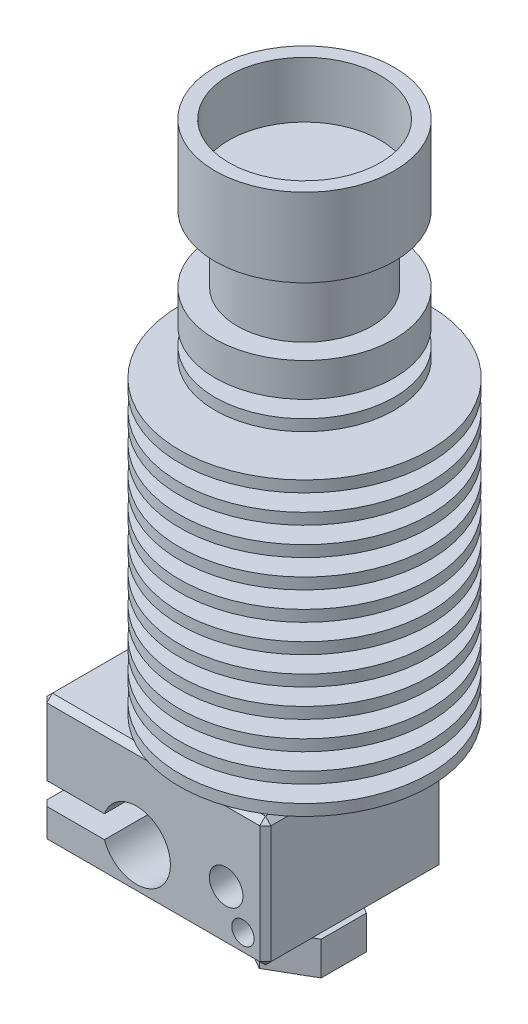
from build123d import *

# Parameters (mm, degrees)
BOSS_EXTRUDE1_DEPTH              = 3
SKETCH2_R                        = 2.5
BOSS_EXTRUDE2_DEPTH              = 1
SKETCH3_W                        = 20
SKETCH3_H                        = 16
BOSS_EXTRUDE3_DEPTH              = 11.5
CUT_EXTRUDE1_DEPTH               = 17
SKETCH5_W                        = 3.025
SKETCH5_H                        = 16
SKETCH8_W                        = 1.5
SKETCH8_H                        = 54.6
F_3_0_3_DIAMETER_HOLE2_D         = 3
F_3_0_3_DIAMETER_HOLE2_DEPTH     = 3.45
F_3_0_3_DIAMETER_HOLE3_D         = 3
F_3_0_3_DIAMETER_HOLE3_DEPTH     = 59.6
M2X0_4_TAPPED_HOLE1_D            = 1.55
M2X0_4_TAPPED_HOLE1_DEPTH        = 4.45
M2X0_4_TAPPED_HOLE1_CBORE_D      = 2
M2X0_4_TAPPED_HOLE1_CBORE_DEPTH  = 2
F_0_4_0_4_DIAMETER_HOLE1_D       = 0.4
F_0_4_0_4_DIAMETER_HOLE1_DEPTH   = 3
F_13_5_13_5_DIAMETER_HOLE1_D     = 13.5
F_13_5_13_5_DIAMETER_HOLE1_DEPTH = 5
CHAMFER1_SIZE                    = 0.5


with BuildPart() as part:
    # Sketch1 → Boss-Extrude1 (new body)
    with BuildSketch(Plane.XZ.offset(42.25)):
        Polygon((-3.5, 2.020725942), (-3.5, -2.020725942), (0, -4.041451884), (3.5, -2.020725942), (3.5, 2.020725942), (0, 4.041451884), align=None)
    extrude(amount=-BOSS_EXTRUDE1_DEPTH)

    # Sketch2 → Boss-Extrude2 (add)
    with BuildSketch(Plane(origin=(0, -39.25, 0), x_dir=(-1, 0, 0), z_dir=(0, 1, 0))):
        Circle(SKETCH2_R)
    extrude(amount=BOSS_EXTRUDE2_DEPTH)

    # Sketch3 → Boss-Extrude3 (add)
    with BuildSketch(Plane.XZ.offset(38.25)):
        with Locations((-5.5, 0)):
            Rectangle(SKETCH3_W, SKETCH3_H)
    extrude(amount=-BOSS_EXTRUDE3_DEPTH)

    # Sketch4 → Cut-Extrude1 (cut, through all)
    with BuildSketch(Plane(origin=(0, 0, -8), x_dir=(-1, 0, 0), z_dir=(0, 0, -1))):
        with BuildLine():
            Line((15.5, -33.25), (9.854929947, -33.25))
            ThreePointArc((9.854929947, -33.25), (10.025, -34.25), (9.854929947, -35.25))
            Line((9.854929947, -35.25), (15.5, -35.25))
            Line((15.5, -35.25), (15.5, -33.25))
        make_face()
    extrude(amount=-CUT_EXTRUDE1_DEPTH, mode=Mode.SUBTRACT)

    # Sketch5 → Cut-Revolve1 (revolve, cut)
    with BuildSketch(Plane.XZ.offset(34.25)):
        with Locations((-5.4875, 0)):
            Rectangle(SKETCH5_W, SKETCH5_H)
    revolve(axis=Axis((-7, -34.25, 8), (0, 0, -1)), mode=Mode.SUBTRACT)

    # Sketch6 → Revolve1 (revolve)
    with BuildSketch(Plane.XY):
        Polygon((1.9, -42.249999999), (0, -42.249999999), (0, -44.25), (0.500000001, -44.25), align=None)
    revolve(axis=Axis((0, -42.249999999, 0), (0, -1, 0)))

    # Sketch7 → Revolve2 (revolve)
    with BuildSketch(Plane.XY):
        Polygon((8, 21.35), (0, 21.35), (0, -26.75), (2, -26.75), (2, -24.65), (11.15, -24.65), (11.15, -23.65), (7, -23.65), (7, -22.15), (11.15, -22.15), (11.15, -21.15), (6.75, -21.15), (6.75, -19.65), (11.15, -19.65), (11.15, -18.65), (6.5, -18.65), (6.5, -17.15), (11.15, -17.15), (11.15, -16.15), (6.25, -16.15), (6.25, -14.65), (11.15, -14.65), (11.15, -13.65), (6, -13.65), (6, -12.15), (11.15, -12.15), (11.15, -11.15), (5.75, -11.15), (5.75, -9.65), (11.15, -9.65), (11.15, -8.65), (5.5, -8.65), (5.5, -7.15), (11.15, -7.15), (11.15, -6.15), (5.25, -6.15), (5.25, -4.65), (11.15, -4.65), (11.15, -3.65), (5, -3.65), (5, -2.15), (11.15, -2.15), (11.15, -1.15), (4.75, -1.15), (4.75, 0.35), (11.15, 0.35), (11.15, 1.35), (4.5, 1.35), (4.5, 2.85), (8, 2.85), (8, 3.85), (4.5, 3.85), (4.5, 5.35), (8, 5.35), (8, 8.35), (6, 8.35), (6, 14.35), (8, 14.35), align=None)
    revolve(axis=Axis((0, 21.35, 0), (0, -1, 0)))

    # Sketch8 → Ø3.0 (3) Diameter Hole1 (revolve, cut)
    with BuildSketch(Plane(origin=(-13, -33.25, 0), x_dir=(0, 0, -1), z_dir=(1, 0, 0))):
        with Locations((0.75, 27.3)):
            Rectangle(SKETCH8_W, SKETCH8_H)
    revolve(axis=Axis((-13, -39.6, 0), (0, 1, 0)), mode=Mode.SUBTRACT)

    # Ø3.0 (3) Diameter Hole2
    with Locations(Plane.XY.offset(8)):
        with Locations((1, -33.45)):
            Hole(F_3_0_3_DIAMETER_HOLE2_D / 2, depth=F_3_0_3_DIAMETER_HOLE2_DEPTH)

    # Ø3.0 (3) Diameter Hole3
    with Locations(Plane(origin=(0, -38.25, 0), x_dir=(-1, 0, 0), z_dir=(0, -1, 0))):
        with Locations((13, 0)):
            Hole(F_3_0_3_DIAMETER_HOLE3_D / 2, depth=F_3_0_3_DIAMETER_HOLE3_DEPTH)

    # M2x0.4 Tapped Hole1
    with Locations(Plane.XY.offset(8)):
        with Locations((2.5, -36.25)):
            CounterBoreHole(M2X0_4_TAPPED_HOLE1_D / 2, M2X0_4_TAPPED_HOLE1_CBORE_D / 2, M2X0_4_TAPPED_HOLE1_CBORE_DEPTH, depth=M2X0_4_TAPPED_HOLE1_DEPTH)

    # Ø0.4 (0.4) Diameter Hole1
    with Locations(Plane(origin=(0, -44.25, 0), x_dir=(-1, 0, 0), z_dir=(0, -1, 0))):
        with Locations((0, 0)):
            Hole(F_0_4_0_4_DIAMETER_HOLE1_D / 2, depth=F_0_4_0_4_DIAMETER_HOLE1_DEPTH)

    # Ø13.5 (13.5) Diameter Hole1
    with Locations(Plane(origin=(0, 21.35, 0), x_dir=(1, 0, 0), z_dir=(0, 1, 0))):
        with Locations((0, 0)):
            Hole(F_13_5_13_5_DIAMETER_HOLE1_D / 2, depth=F_13_5_13_5_DIAMETER_HOLE1_DEPTH)

    # Chamfer1
    chamfer1_edges = [part.edges().sort_by_distance(p)[0] for p in [
        (-15.5, -26.75, 0),
        (-15.5, -30, -8),
        (-5.5, -26.75, 8),
        (-15.5, -30, 8),
        (4.5, -26.75, 0),
        (4.5, -32.5, 8),
        (-5.5, -26.75, -8),
        (4.5, -32.5, -8),
        (-15.5, -38.25, 0),
        (-5.5, -38.25, -8),
        (4.5, -38.25, 0),
        (-5.5, -38.25, 8),
        (-15.5, -36.75, -8),
        (-15.5, -36.75, 8),
    ]]
    chamfer(chamfer1_edges, length=CHAMFER1_SIZE)


solid = part.part
